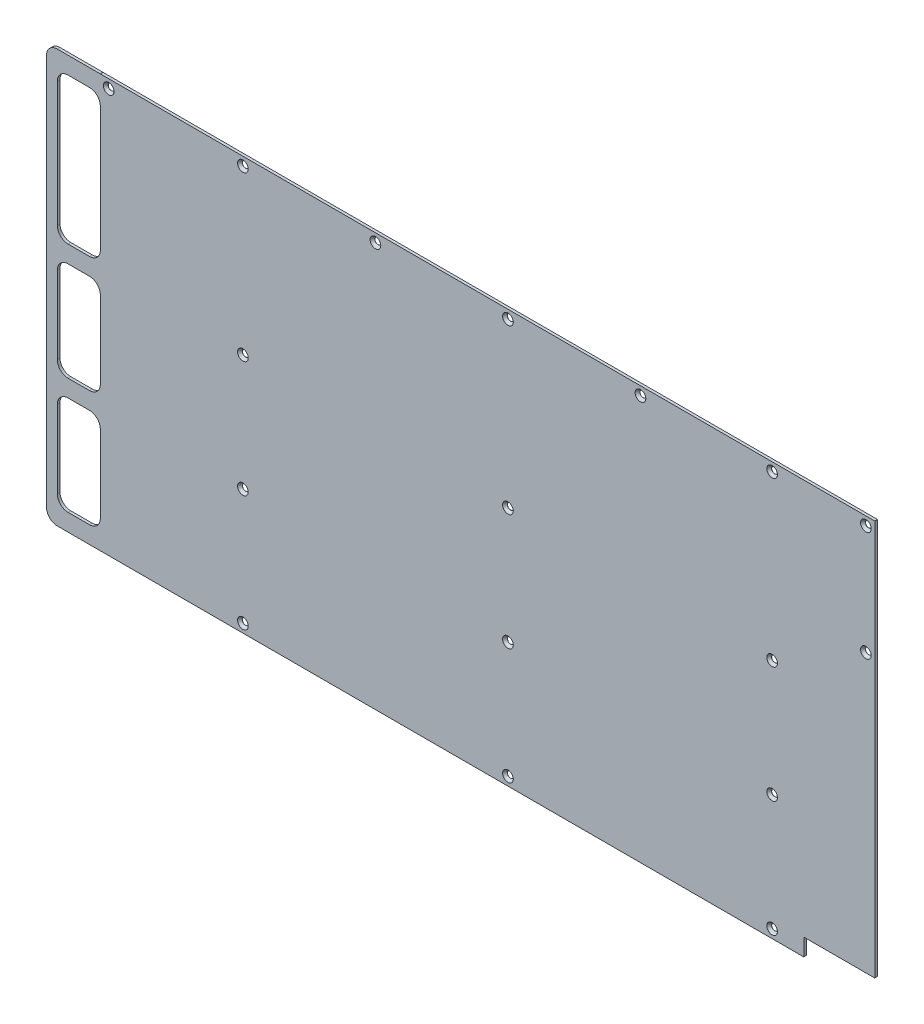
from build123d import *

# Parameters (mm, degrees)
MODEL_R                                       = 1.8288
BOSS_EXTRUDE2_DEPTH                           = 1.5875
CSK_FOR_6_FLAT_HEAD_MACHINE_SCREW2_AT_2_COUNT = 2
CSK_FOR_6_FLAT_HEAD_MACHINE_SCREW2_AT_2_PITCH = 79.248
CSK_FOR_6_FLAT_HEAD_MACHINE_SCREW2_AT_3_COUNT = 2
CSK_FOR_6_FLAT_HEAD_MACHINE_SCREW2_AT_3_PITCH = 157.48
CSK_FOR_6_FLAT_HEAD_MACHINE_SCREW2_AT_4_COUNT = 2
CSK_FOR_6_FLAT_HEAD_MACHINE_SCREW2_AT_4_PITCH = 235.712
CSK_FOR_6_FLAT_HEAD_MACHINE_SCREW2_AT_5_COUNT = 2
CSK_FOR_6_FLAT_HEAD_MACHINE_SCREW2_AT_5_PITCH = 313.944
CSK_FOR_6_FLAT_HEAD_MACHINE_SCREW2_AT_6_COUNT = 2
CSK_FOR_6_FLAT_HEAD_MACHINE_SCREW2_AT_6_PITCH = 391.668
CSK_FOR_6_FLAT_HEAD_MACHINE_SCREW2_AT_7_COUNT = 2
CSK_FOR_6_FLAT_HEAD_MACHINE_SCREW2_AT_7_PITCH = 447.04
CSK_FOR_6_FLAT_HEAD_MACHINE_SCREW2_AT_8_COUNT = 2
CSK_FOR_6_FLAT_HEAD_MACHINE_SCREW2_AT_8_PITCH = 451.707775558
CSK_FOR_6_FLAT_HEAD_MACHINE_SCREW2_AT_9_COUNT = 2
CSK_FOR_6_FLAT_HEAD_MACHINE_SCREW2_AT_9_PITCH = 403.385588022
CSK_FOR_6_FLAT_HEAD_MACHINE_SCREW2_AT_1_COUNT = 2
CSK_FOR_6_FLAT_HEAD_MACHINE_SCREW2_AT_1_PITCH = 425.043329819
CSK_FOR_6_FLAT_HEAD_MACHINE_SCREW2_2_COUNT    = 2
CSK_FOR_6_FLAT_HEAD_MACHINE_SCREW2_2_PITCH    = 456.08131361
CSK_FOR_6_FLAT_HEAD_MACHINE_SCREW2_3_COUNT    = 2
CSK_FOR_6_FLAT_HEAD_MACHINE_SCREW2_3_PITCH    = 331.913376266
CSK_FOR_6_FLAT_HEAD_MACHINE_SCREW2_4_COUNT    = 2
CSK_FOR_6_FLAT_HEAD_MACHINE_SCREW2_4_PITCH    = 287.78143954
CSK_FOR_6_FLAT_HEAD_MACHINE_SCREW2_5_COUNT    = 2
CSK_FOR_6_FLAT_HEAD_MACHINE_SCREW2_5_PITCH    = 254.708180756
CSK_FOR_6_FLAT_HEAD_MACHINE_SCREW2_6_COUNT    = 2
CSK_FOR_6_FLAT_HEAD_MACHINE_SCREW2_6_PITCH    = 124.885371057
CSK_FOR_6_FLAT_HEAD_MACHINE_SCREW2_7_COUNT    = 2
CSK_FOR_6_FLAT_HEAD_MACHINE_SCREW2_7_PITCH    = 183.134528432
CSK_FOR_6_FLAT_HEAD_MACHINE_SCREW2_8_COUNT    = 2
CSK_FOR_6_FLAT_HEAD_MACHINE_SCREW2_8_PITCH    = 246.752077811


with BuildPart() as part:
    # Model → Boss-Extrude2 (new body)
    with BuildSketch(Plane.XY):
        with BuildLine():
            Line((-25.251805612, 0), (0.148194388, 0))
            Line((0.148194388, 0), (415.374694388, 0))
            ThreePointArc((415.374694388, 0), (415.393293107, 0.044901281), (415.438194388, 0.0635))
            Line((415.438194388, 0.0635), (415.438194388, 10.0965))
            ThreePointArc((415.438194388, 10.0965), (415.393293107, 10.204901281), (415.501694388, 10.16))
            Line((415.501694388, 10.16), (457.284694388, 10.16))
            ThreePointArc((457.284694388, 10.16), (457.303293107, 10.204901281), (457.348194388, 10.2235))
            Line((457.348194388, 10.2235), (457.348194388, 243.7765))
            ThreePointArc((457.348194388, 243.7765), (457.303293107, 243.795098719), (457.284694388, 243.84))
            Line((457.284694388, 243.84), (0.211694388, 243.84))
            ThreePointArc((0.211694388, 243.84), (0.193095668, 243.795098719), (0.148194388, 243.7765))
            ThreePointArc((0.148194388, 243.7765), (0.103293107, 243.795098719), (0.084694388, 243.84))
            Line((0.084694388, 243.84), (-25.251805612, 243.84))
            ThreePointArc((-25.251805612, 243.84), (-29.741933673, 241.980128061), (-31.601805612, 237.49))
            Line((-31.601805612, 237.49), (-31.601805612, 6.35))
            ThreePointArc((-31.601805612, 6.35), (-29.741933673, 1.859871939), (-25.251805612, 0))
        make_face()
        with Locations((84.328, 5.08)):
            Circle(MODEL_R, mode=Mode.SUBTRACT)
        with BuildLine():
            Line((-18.901805612, 68.58), (-6.201805612, 68.58))
            ThreePointArc((-6.201805612, 68.58), (-1.711677552, 66.720128061), (0.148194388, 62.23))
            Line((0.148194388, 62.23), (0.148194388, 16.51))
            ThreePointArc((0.148194388, 16.51), (-1.711677552, 12.019871939), (-6.201805612, 10.16))
            Line((-6.201805612, 10.16), (-18.901805612, 10.16))
            ThreePointArc((-18.901805612, 10.16), (-23.391933673, 12.019871939), (-25.251805612, 16.51))
            Line((-25.251805612, 16.51), (-25.251805612, 62.23))
            ThreePointArc((-25.251805612, 62.23), (-23.391933673, 66.720128061), (-18.901805612, 68.58))
        make_face(mode=Mode.SUBTRACT)
        with Locations((84.328, 73.66)):
            Circle(MODEL_R, mode=Mode.SUBTRACT)
        with BuildLine():
            Line((-18.901805612, 137.16), (-6.201805612, 137.16))
            ThreePointArc((-6.201805612, 137.16), (-1.711677552, 135.300128061), (0.148194388, 130.81))
            Line((0.148194388, 130.81), (0.148194388, 85.09))
            ThreePointArc((0.148194388, 85.09), (-1.711677552, 80.599871939), (-6.201805612, 78.74))
            Line((-6.201805612, 78.74), (-18.901805612, 78.74))
            ThreePointArc((-18.901805612, 78.74), (-23.391933673, 80.599871939), (-25.251805612, 85.09))
            Line((-25.251805612, 85.09), (-25.251805612, 130.81))
            ThreePointArc((-25.251805612, 130.81), (-23.391933673, 135.300128061), (-18.901805612, 137.16))
        make_face(mode=Mode.SUBTRACT)
        with Locations((240.792, 5.08)):
            Circle(MODEL_R, mode=Mode.SUBTRACT)
        with Locations((396.748, 5.08)):
            Circle(MODEL_R, mode=Mode.SUBTRACT)
        with Locations((240.792, 73.66)):
            Circle(MODEL_R, mode=Mode.SUBTRACT)
        with Locations((396.748, 73.66)):
            Circle(MODEL_R, mode=Mode.SUBTRACT)
        with Locations((84.328, 142.24)):
            Circle(MODEL_R, mode=Mode.SUBTRACT)
        with BuildLine():
            ThreePointArc((-6.201805612, 233.68), (-1.711677552, 231.820128061), (0.148194388, 227.33))
            Line((0.148194388, 227.33), (0.148194388, 153.67))
            ThreePointArc((0.148194388, 153.67), (-1.711677552, 149.179871939), (-6.201805612, 147.32))
            Line((-6.201805612, 147.32), (-18.901805612, 147.32))
            ThreePointArc((-18.901805612, 147.32), (-23.391933673, 149.179871939), (-25.251805612, 153.67))
            Line((-25.251805612, 153.67), (-25.251805612, 227.33))
            ThreePointArc((-25.251805612, 227.33), (-23.391933673, 231.820128061), (-18.901805612, 233.68))
            Line((-18.901805612, 233.68), (-6.201805612, 233.68))
        make_face(mode=Mode.SUBTRACT)
        with Locations((5.08, 238.76)):
            Circle(MODEL_R, mode=Mode.SUBTRACT)
        with Locations((84.328, 238.76)):
            Circle(MODEL_R, mode=Mode.SUBTRACT)
        with Locations((162.56, 238.76)):
            Circle(MODEL_R, mode=Mode.SUBTRACT)
        with Locations((240.792, 142.24)):
            Circle(MODEL_R, mode=Mode.SUBTRACT)
        with Locations((396.748, 142.24)):
            Circle(MODEL_R, mode=Mode.SUBTRACT)
        with Locations((452.12, 173.99)):
            Circle(MODEL_R, mode=Mode.SUBTRACT)
        with Locations((240.792, 238.76)):
            Circle(MODEL_R, mode=Mode.SUBTRACT)
        with Locations((319.024, 238.76)):
            Circle(MODEL_R, mode=Mode.SUBTRACT)
        with Locations((396.748, 238.76)):
            Circle(MODEL_R, mode=Mode.SUBTRACT)
        with Locations((452.12, 238.76)):
            Circle(MODEL_R, mode=Mode.SUBTRACT)
    extrude(amount=BOSS_EXTRUDE2_DEPTH)

    # Sketch4 → CSK for #6 Flat Head Machine Screw2 (revolve, cut)
    with BuildSketch(Plane(origin=(5.08, 238.76, 1.5875), x_dir=(0, -1, 0), z_dir=(1, 0, 0))):
        Polygon((0, 0), (0, 1.5875), (1.8288, 1.5875), (1.8288, 1.519406592), (3.1496, 0), align=None)
    csk_for_6_flat_head_machine_screw2 = revolve(axis=Axis((5.08, 238.76, 7.9375), (0, 0, -1)), mode=Mode.SUBTRACT)

    # CSK for #6 Flat Head Machine Screw2 at 2: CSK for #6 Flat Head Machine Screw2 ×2
    with Locations(*[(i * CSK_FOR_6_FLAT_HEAD_MACHINE_SCREW2_AT_2_PITCH, 0, 0) for i in range(1, CSK_FOR_6_FLAT_HEAD_MACHINE_SCREW2_AT_2_COUNT)]):
        add(csk_for_6_flat_head_machine_screw2, mode=Mode.SUBTRACT)

    # CSK for #6 Flat Head Machine Screw2 at 3: CSK for #6 Flat Head Machine Screw2 ×2
    with Locations(*[(i * CSK_FOR_6_FLAT_HEAD_MACHINE_SCREW2_AT_3_PITCH, 0, 0) for i in range(1, CSK_FOR_6_FLAT_HEAD_MACHINE_SCREW2_AT_3_COUNT)]):
        add(csk_for_6_flat_head_machine_screw2, mode=Mode.SUBTRACT)

    # CSK for #6 Flat Head Machine Screw2 at 4: CSK for #6 Flat Head Machine Screw2 ×2
    with Locations(*[(i * CSK_FOR_6_FLAT_HEAD_MACHINE_SCREW2_AT_4_PITCH, 0, 0) for i in range(1, CSK_FOR_6_FLAT_HEAD_MACHINE_SCREW2_AT_4_COUNT)]):
        add(csk_for_6_flat_head_machine_screw2, mode=Mode.SUBTRACT)

    # CSK for #6 Flat Head Machine Screw2 at 5: CSK for #6 Flat Head Machine Screw2 ×2
    with Locations(*[(i * CSK_FOR_6_FLAT_HEAD_MACHINE_SCREW2_AT_5_PITCH, 0, 0) for i in range(1, CSK_FOR_6_FLAT_HEAD_MACHINE_SCREW2_AT_5_COUNT)]):
        add(csk_for_6_flat_head_machine_screw2, mode=Mode.SUBTRACT)

    # CSK for #6 Flat Head Machine Screw2 at 6: CSK for #6 Flat Head Machine Screw2 ×2
    with Locations(*[(i * CSK_FOR_6_FLAT_HEAD_MACHINE_SCREW2_AT_6_PITCH, 0, 0) for i in range(1, CSK_FOR_6_FLAT_HEAD_MACHINE_SCREW2_AT_6_COUNT)]):
        add(csk_for_6_flat_head_machine_screw2, mode=Mode.SUBTRACT)

    # CSK for #6 Flat Head Machine Screw2 at 7: CSK for #6 Flat Head Machine Screw2 ×2
    with Locations(*[(i * CSK_FOR_6_FLAT_HEAD_MACHINE_SCREW2_AT_7_PITCH, 0, 0) for i in range(1, CSK_FOR_6_FLAT_HEAD_MACHINE_SCREW2_AT_7_COUNT)]):
        add(csk_for_6_flat_head_machine_screw2, mode=Mode.SUBTRACT)

    # CSK for #6 Flat Head Machine Screw2 at 8: CSK for #6 Flat Head Machine Screw2 ×2
    with Locations(*[Vector(0.989666382, -0.143389163, 0) * (i * CSK_FOR_6_FLAT_HEAD_MACHINE_SCREW2_AT_8_PITCH) for i in range(1, CSK_FOR_6_FLAT_HEAD_MACHINE_SCREW2_AT_8_COUNT)]):
        add(csk_for_6_flat_head_machine_screw2, mode=Mode.SUBTRACT)

    # CSK for #6 Flat Head Machine Screw2 at 9: CSK for #6 Flat Head Machine Screw2 ×2
    with Locations(*[Vector(0.970951892, -0.239274785, 0) * (i * CSK_FOR_6_FLAT_HEAD_MACHINE_SCREW2_AT_9_PITCH) for i in range(1, CSK_FOR_6_FLAT_HEAD_MACHINE_SCREW2_AT_9_COUNT)]):
        add(csk_for_6_flat_head_machine_screw2, mode=Mode.SUBTRACT)

    # CSK for #6 Flat Head Machine Screw2 at 1: CSK for #6 Flat Head Machine Screw2 ×2
    with Locations(*[Vector(0.921477818, -0.388430987, 0) * (i * CSK_FOR_6_FLAT_HEAD_MACHINE_SCREW2_AT_1_PITCH) for i in range(1, CSK_FOR_6_FLAT_HEAD_MACHINE_SCREW2_AT_1_COUNT)]):
        add(csk_for_6_flat_head_machine_screw2, mode=Mode.SUBTRACT)

    # CSK for #6 Flat Head Machine Screw2  2: CSK for #6 Flat Head Machine Screw2 ×2
    with Locations(*[Vector(0.858767918, -0.512364776, 0) * (i * CSK_FOR_6_FLAT_HEAD_MACHINE_SCREW2_2_PITCH) for i in range(1, CSK_FOR_6_FLAT_HEAD_MACHINE_SCREW2_2_COUNT)]):
        add(csk_for_6_flat_head_machine_screw2, mode=Mode.SUBTRACT)

    # CSK for #6 Flat Head Machine Screw2  3: CSK for #6 Flat Head Machine Screw2 ×2
    with Locations(*[Vector(0.710161195, -0.704039116, 0) * (i * CSK_FOR_6_FLAT_HEAD_MACHINE_SCREW2_3_PITCH) for i in range(1, CSK_FOR_6_FLAT_HEAD_MACHINE_SCREW2_3_COUNT)]):
        add(csk_for_6_flat_head_machine_screw2, mode=Mode.SUBTRACT)

    # CSK for #6 Flat Head Machine Screw2  4: CSK for #6 Flat Head Machine Screw2 ×2
    with Locations(*[Vector(0.819066026, -0.573699264, 0) * (i * CSK_FOR_6_FLAT_HEAD_MACHINE_SCREW2_4_PITCH) for i in range(1, CSK_FOR_6_FLAT_HEAD_MACHINE_SCREW2_4_COUNT)]):
        add(csk_for_6_flat_head_machine_screw2, mode=Mode.SUBTRACT)

    # CSK for #6 Flat Head Machine Screw2  5: CSK for #6 Flat Head Machine Screw2 ×2
    with Locations(*[Vector(0.925419825, -0.378943463, 0) * (i * CSK_FOR_6_FLAT_HEAD_MACHINE_SCREW2_5_PITCH) for i in range(1, CSK_FOR_6_FLAT_HEAD_MACHINE_SCREW2_5_COUNT)]):
        add(csk_for_6_flat_head_machine_screw2, mode=Mode.SUBTRACT)

    # CSK for #6 Flat Head Machine Screw2  6: CSK for #6 Flat Head Machine Screw2 ×2
    with Locations(*[Vector(0.634565917, -0.772868745, 0) * (i * CSK_FOR_6_FLAT_HEAD_MACHINE_SCREW2_6_PITCH) for i in range(1, CSK_FOR_6_FLAT_HEAD_MACHINE_SCREW2_6_COUNT)]):
        add(csk_for_6_flat_head_machine_screw2, mode=Mode.SUBTRACT)

    # CSK for #6 Flat Head Machine Screw2  7: CSK for #6 Flat Head Machine Screw2 ×2
    with Locations(*[Vector(0.432731068, -0.901523057, 0) * (i * CSK_FOR_6_FLAT_HEAD_MACHINE_SCREW2_7_PITCH) for i in range(1, CSK_FOR_6_FLAT_HEAD_MACHINE_SCREW2_7_COUNT)]):
        add(csk_for_6_flat_head_machine_screw2, mode=Mode.SUBTRACT)

    # CSK for #6 Flat Head Machine Screw2  8: CSK for #6 Flat Head Machine Screw2 ×2
    with Locations(*[Vector(0.321164469, -0.947023434, 0) * (i * CSK_FOR_6_FLAT_HEAD_MACHINE_SCREW2_8_PITCH) for i in range(1, CSK_FOR_6_FLAT_HEAD_MACHINE_SCREW2_8_COUNT)]):
        add(csk_for_6_flat_head_machine_screw2, mode=Mode.SUBTRACT)


solid = part.part
